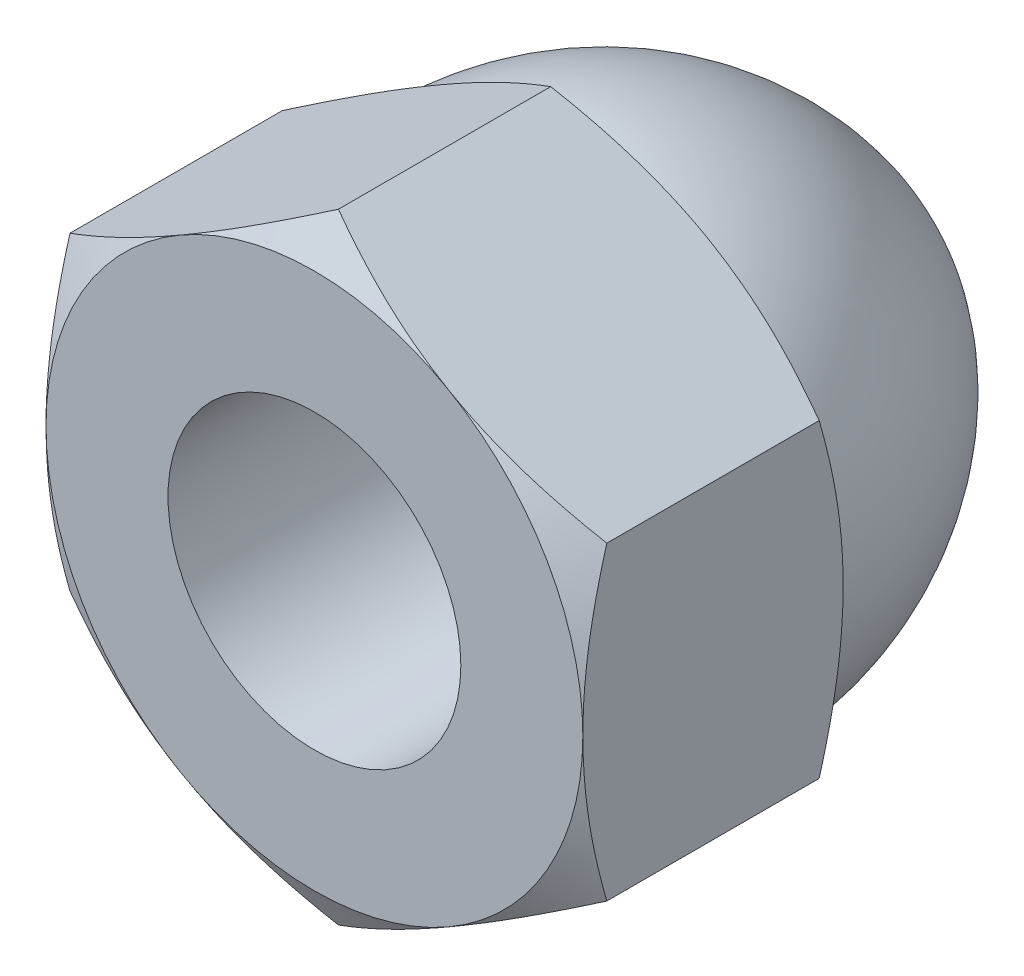
from build123d import *

# Parameters (mm, degrees)
EXTRUDE1_DEPTH     = 2.666666667
SKETCH2_OUTSIDE_W  = 29.964
SKETCH2_OUTSIDE_H  = 30.814
SKETCH2_OUTSIDE_R  = 2.75
CUT_EXTRUDE1_DEPTH = 5.97563508
CUT_EXTRUDE1_DRAFT = -60
SKETCH3_OUTSIDE_W  = 29.964
SKETCH3_OUTSIDE_H  = 30.814
SKETCH3_OUTSIDE_R  = 2.75
CUT_EXTRUDE2_DEPTH = 5.97563508
CUT_EXTRUDE2_DRAFT = -60
SKETCH4_R          = 1.5
CUT_EXTRUDE3_DEPTH = 5


with BuildPart() as part:
    # Sketch1 → Extrude1 (new body)
    with BuildSketch(Plane.XY):
        Polygon((0, 3.175426481), (-2.75, 1.58771324), (-2.75, -1.58771324), (0, -3.175426481), (2.75, -1.58771324), (2.75, 1.58771324), align=None)
    extrude(amount=-EXTRUDE1_DEPTH)


with BuildPart() as cut_extrude1_tool:
    # Sketch2 outside → Cut-Extrude1 (with draft: the straight prism first)
    with BuildSketch(Plane.XY):
        Rectangle(SKETCH2_OUTSIDE_W, SKETCH2_OUTSIDE_H)
        Circle(SKETCH2_OUTSIDE_R, mode=Mode.SUBTRACT)
    extrude(amount=-CUT_EXTRUDE1_DEPTH)
    # Cut-Extrude1: the draft: its side faces are tilted about the plane it starts from
    cut_extrude1_sides = [cut_extrude1_tool.faces().sort_by_distance(p)[0] for p in [
        (0, -15.407, -2.98781754),
        (14.982, 0, -2.98781754),
        (0, 15.407, -2.98781754),
        (-14.982, 0, -2.98781754),
        (-2.75, 0, -2.98781754),
    ]]
    draft(cut_extrude1_sides, Plane.XY, CUT_EXTRUDE1_DRAFT)


with BuildPart() as part_1:
    add(part.part)

    # Cut-Extrude1: cut by cut_extrude1_tool
    add(cut_extrude1_tool.part, mode=Mode.SUBTRACT)


with BuildPart() as cut_extrude2_tool:
    # Sketch3 outside → Cut-Extrude2 (with draft: the straight prism first)
    with BuildSketch(Plane(origin=(0, 0, -2.666666667), x_dir=(-1, 0, 0), z_dir=(0, 0, -1))):
        Rectangle(SKETCH3_OUTSIDE_W, SKETCH3_OUTSIDE_H)
        Circle(SKETCH3_OUTSIDE_R, mode=Mode.SUBTRACT)
    extrude(amount=-CUT_EXTRUDE2_DEPTH)
    # Cut-Extrude2: the draft: its side faces are tilted about the plane it starts from
    cut_extrude2_sides = [cut_extrude2_tool.faces().sort_by_distance(p)[0] for p in [
        (0, -15.407, 0.321150873),
        (-14.982, 0, 0.321150873),
        (0, 15.407, 0.321150873),
        (14.982, 0, 0.321150873),
        (2.75, 0, 0.321150873),
    ]]
    draft(cut_extrude2_sides, Plane(origin=(0, 0, -2.666666667), x_dir=(-1, 0, 0), z_dir=(0, 0, -1)), CUT_EXTRUDE2_DRAFT)


with BuildPart() as part_2:
    add(part_1.part)

    # Cut-Extrude2: cut by cut_extrude2_tool
    add(cut_extrude2_tool.part, mode=Mode.SUBTRACT)

    # Sketch14 → Revolve1 (revolve)
    with BuildSketch(Plane(origin=(0, 0, 0), x_dir=(0, 0, -1), z_dir=(1, 0, 0))):
        with BuildLine():
            Line((2.666666667, 2.7225), (2.666666667, 0))
            Line((2.666666667, 0), (6, 0))
            ThreePointArc((6, 0), (4.818591233, 1.955382721), (2.666666667, 2.7225))
        make_face()
    revolve(axis=Axis((0, 0, 0), (0, 0, -1)))

    # Sketch4 → Cut-Extrude3 (cut)
    with BuildSketch(Plane.XY):
        Circle(SKETCH4_R)
    extrude(amount=-CUT_EXTRUDE3_DEPTH, mode=Mode.SUBTRACT)

    # Sketch20 → Cut-Revolve1 (revolve, cut)
    with BuildSketch(Plane(origin=(0, 0, 0), x_dir=(0, 0, -1), z_dir=(1, 0, 0))):
        Polygon((5.166666667, 1.5), (6.03269207, 0), (5, 0), (5, 1.5), align=None)
    revolve(axis=Axis((0, 0, 0), (0, 0, 1)), mode=Mode.SUBTRACT)


solid = part_2.part
